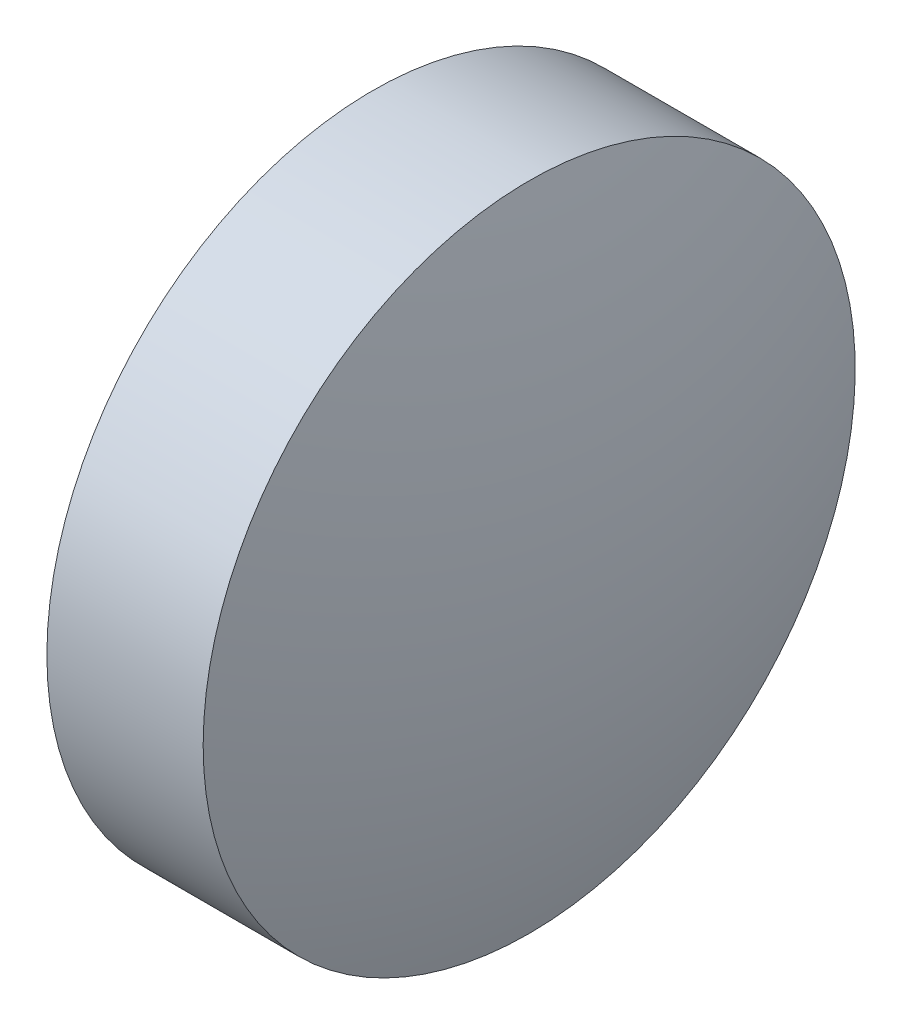
from build123d import *


with BuildPart() as part:
    # 草图1 → 旋转1 (revolve)
    with BuildSketch(Plane.XY, mode=Mode.PRIVATE) as revolve_1_sk:
        with BuildLine():
            Line((564.353466832, 45.464632005), (564.353466832, 48.614632005))
            Line((564.353466832, 48.614632005), (565.863466832, 48.614632005))
            ThreePointArc((565.863466832, 48.614632005), (566.230234615, 47.05857366), (566.353466832, 45.464632005))
            Line((566.353466832, 45.464632005), (564.353466832, 45.464632005))
        make_face()
    revolve(revolve_1_sk.sketch.rotate(Axis((563.491838662, 45.464632005, 0), (1, 0, 0)), 180), axis=Axis((563.491838662, 45.464632005, 0), (1, 0, 0)))  # turned: the seam where the file's is


solid = part.part
